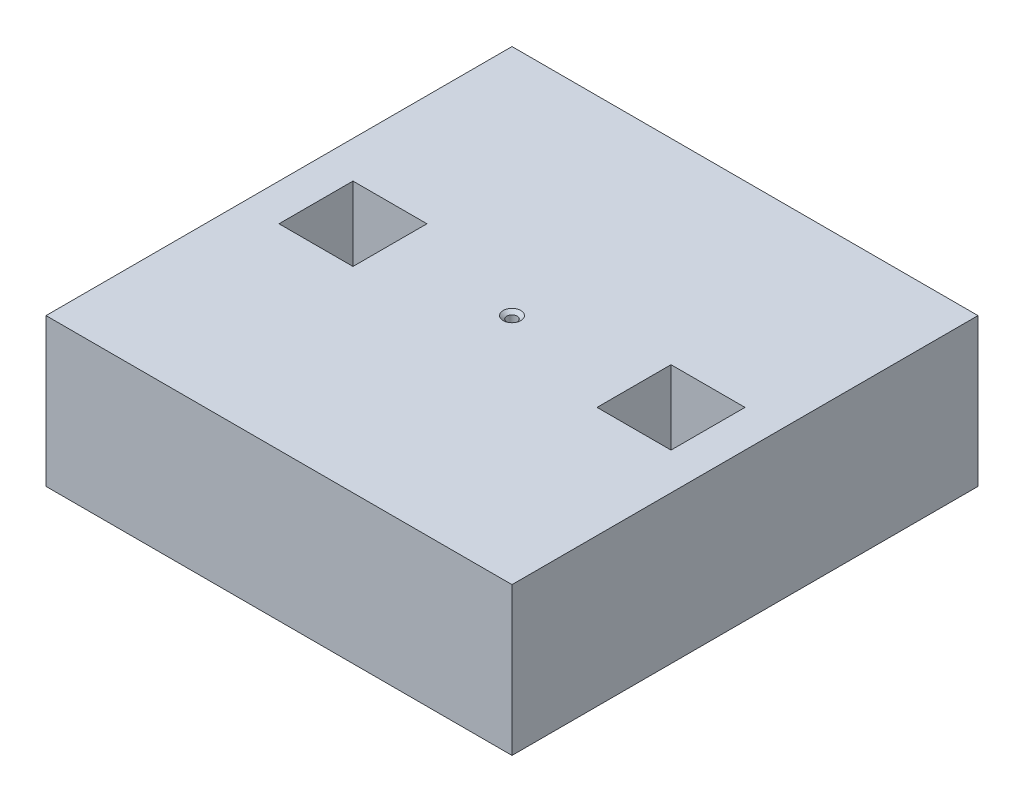
from build123d import *

# Parameters (mm, degrees)
SKETCH1_W                                         = 80
SKETCH1_H                                         = 80
SKETCH1_W_2                                       = 12.7
SKETCH1_H_2                                       = 12.7
BOSS_EXTRUDE1_DEPTH                               = 25.4
CSK_FOR_0_FLAT_HEAD_MACHINE_SCREW_100_D           = 1.778
CSK_FOR_0_FLAT_HEAD_MACHINE_SCREW_100_CSINK_D     = 3.0226
CSK_FOR_0_FLAT_HEAD_MACHINE_SCREW_100_CSINK_ANGLE = 100


with BuildPart() as part:
    # Sketch1 → Boss-Extrude1 (new body)
    with BuildSketch(Plane(origin=(0, 0, 0), x_dir=(1, 0, 0), z_dir=(0, 1, 0))):
        Rectangle(SKETCH1_W, SKETCH1_H)
        with Locations((-27.3, 0)):
            Rectangle(SKETCH1_W_2, SKETCH1_H_2, mode=Mode.SUBTRACT)
        with Locations((27.3, 0)):
            Rectangle(SKETCH1_W_2, SKETCH1_H_2, mode=Mode.SUBTRACT)
    extrude(amount=BOSS_EXTRUDE1_DEPTH)

    # CSK for #0 Flat Head Machine Screw (100)1 (through all)
    with Locations(Plane(origin=(0, 25.4, 0), x_dir=(1, 0, 0), z_dir=(0, 1, 0))):
        with Locations((0, 0)):
            CounterSinkHole(CSK_FOR_0_FLAT_HEAD_MACHINE_SCREW_100_D / 2, CSK_FOR_0_FLAT_HEAD_MACHINE_SCREW_100_CSINK_D / 2, counter_sink_angle=CSK_FOR_0_FLAT_HEAD_MACHINE_SCREW_100_CSINK_ANGLE)


solid = part.part
